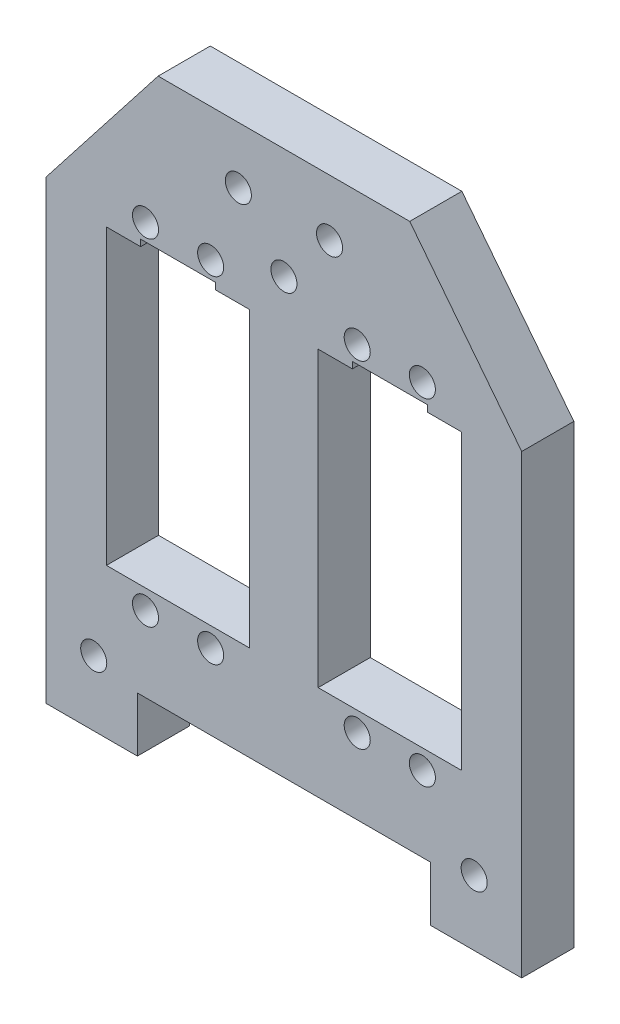
from build123d import *

# Parameters (mm, degrees)
ESBO_O1_R                = 2
RESSALTO_EXTRUS_O1_DEPTH = 8


with BuildPart() as part:
    # Esboço1 → Ressalto-extrusão1 (new body)
    with BuildSketch(Plane.XY):
        Polygon((19.311716217, 17), (-19.311716217, 17), (-36.5, -5), (-36.5, -75), (-22.499999998, -75), (-22.499999998, -66.599999996), (22.499999998, -66.599999996), (22.499999998, -75), (36.5, -75), (36.5, -5), align=None)
        with Locations((-21.250245, -3.420107551)):
            Circle(ESBO_O1_R, mode=Mode.SUBTRACT)
        with Locations((-11.250245, -55.019882032)):
            Circle(ESBO_O1_R, mode=Mode.SUBTRACT)
        with Locations((11.250245, -3.420107551)):
            Circle(ESBO_O1_R, mode=Mode.SUBTRACT)
        with Locations((21.250245, -55.019882032)):
            Circle(ESBO_O1_R, mode=Mode.SUBTRACT)
        with Locations((-21.250245, -55.019882032)):
            Circle(ESBO_O1_R, mode=Mode.SUBTRACT)
        with Locations((-11.250245, -3.420107551)):
            Circle(ESBO_O1_R, mode=Mode.SUBTRACT)
        with Locations((11.250245, -55.019882032)):
            Circle(ESBO_O1_R, mode=Mode.SUBTRACT)
        with Locations((21.250245, -3.420107551)):
            Circle(ESBO_O1_R, mode=Mode.SUBTRACT)
        Circle(ESBO_O1_R, mode=Mode.SUBTRACT)
        with Locations((-7, 8.3)):
            Circle(ESBO_O1_R, mode=Mode.SUBTRACT)
        with Locations((7, 8.3)):
            Circle(ESBO_O1_R, mode=Mode.SUBTRACT)
        with Locations((-29.2, -65)):
            Circle(ESBO_O1_R, mode=Mode.SUBTRACT)
        with Locations((29.2, -65)):
            Circle(ESBO_O1_R, mode=Mode.SUBTRACT)
        Polygon((-27.250245, -29.520107551), (-27.250245, -7.020107551), (-22.000245, -7.020107551), (-22.000245, -6.020107551), (-10.500245, -6.020107551), (-10.500245, -7.020107551), (-5.250245, -7.020107551), (-5.250245, -29.520107551), (-5.250245, -52.020107551), (-27.250245, -52.020107551), align=None, mode=Mode.SUBTRACT)
        Polygon((10.500245, -7.020107551), (5.250245, -7.020107551), (5.250245, -29.520107551), (5.250245, -52.020107551), (27.250245, -52.020107551), (27.250245, -29.520107551), (27.250245, -7.020107551), (22.000245, -7.020107551), (22.000245, -6.020107551), (10.500245, -6.020107551), align=None, mode=Mode.SUBTRACT)
    extrude(amount=RESSALTO_EXTRUS_O1_DEPTH)


solid = part.part
